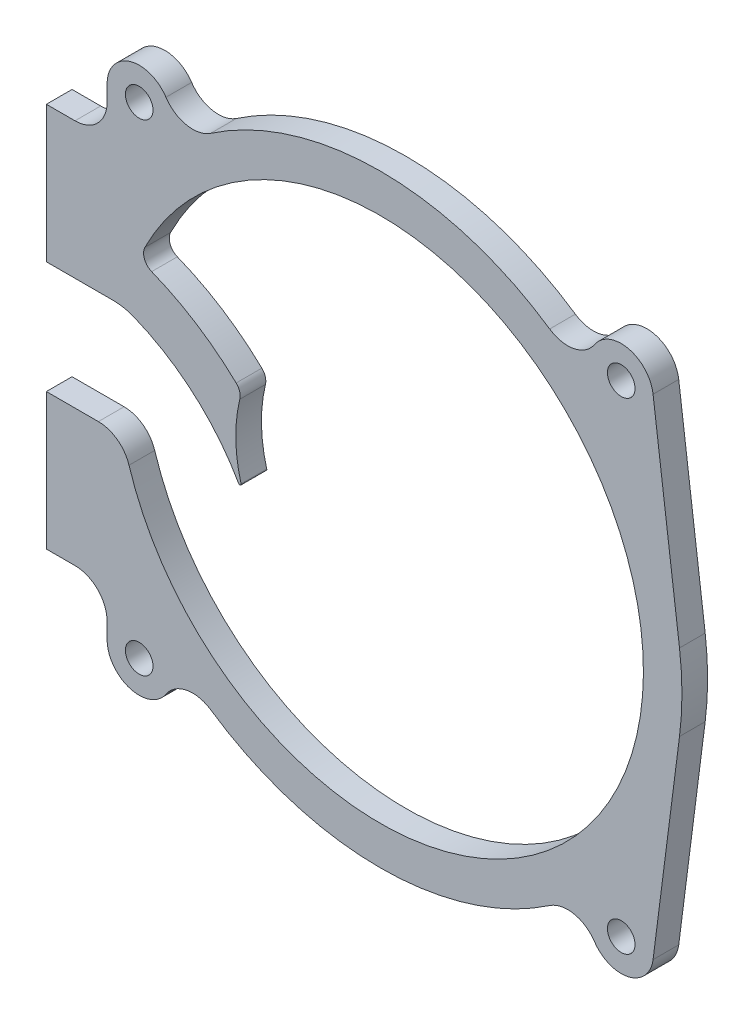
from build123d import *

# Parameters (mm, degrees)
SKETCH_1_R      = 2.15
EXTRUDE_1_DEPTH = 4
FILLET_1_R      = 0.2
FILLET_2_R      = 2
FILLET_3_R      = 2
FILLET_4_R      = 8.5
FILLET_5_R      = 5


with BuildPart() as part:
    # 草图1 → 凸台-拉伸1 (new body)
    with BuildSketch(Plane.XY):
        with BuildLine():
            Line((-52, 8.75), (-52, 30))
            Line((-52, 30), (-47.54, 30))
            ThreePointArc((-47.54, 30), (-44.004466094, 31.464466094), (-42.54, 35))
            Line((-42.54, 35), (-42.54, 37.5))
            ThreePointArc((-42.54, 37.5), (-38.982425028, 42.287422066), (-33.372235985, 40.262198963))
            ThreePointArc((-33.372235985, 40.262198963), (-30.171244586, 38.118753147), (-26.396349665, 38.887436588))
            ThreePointArc((-26.396349665, 38.887436588), (0, 47), (26.396349665, 38.887436588))
            ThreePointArc((26.396349665, 38.887436588), (30.171244586, 38.118753147), (33.372235985, 40.262198963))
            ThreePointArc((33.372235985, 40.262198963), (38.674773042, 42.369526686), (42.499484755, 38.135225128))
            Line((42.499484755, 38.135225128), (46.619156699, 5.971116201))
            ThreePointArc((46.619156699, 5.971116201), (47, 0), (46.619156699, -5.971116201))
            Line((46.619156699, -5.971116201), (42.499484755, -38.135225128))
            ThreePointArc((42.499484755, -38.135225128), (38.674773042, -42.369526686), (33.372235985, -40.262198963))
            ThreePointArc((33.372235985, -40.262198963), (30.171244586, -38.118753147), (26.396349665, -38.887436588))
            ThreePointArc((26.396349665, -38.887436588), (0, -47), (-26.396349665, -38.887436588))
            ThreePointArc((-26.396349665, -38.887436588), (-30.171244586, -38.118753147), (-33.372235985, -40.262198963))
            ThreePointArc((-33.372235985, -40.262198963), (-38.982425028, -42.287422066), (-42.54, -37.5))
            Line((-42.54, -37.5), (-42.54, -35))
            ThreePointArc((-42.54, -35), (-44.004466094, -31.464466094), (-47.54, -30))
            Line((-47.54, -30), (-52, -30))
            Line((-52, -30), (-52, -8.75))
            Line((-52, -8.75), (-40.055430343, -8.75))
            ThreePointArc((-40.055430343, -8.75), (40.804364959, -4.000475011), (-37.593370285, 16.362717092))
            ThreePointArc((-37.593370285, 16.362717092), (-29.005163231, 12.290176631), (-21.585495377, 6.349518825))
            ThreePointArc((-21.585495377, 6.349518825), (-22.451945258, -1.469746278), (-20.573530425, -9.10932741))
            ThreePointArc((-20.573530425, -9.10932741), (-28.44850534, 1.855840669), (-40.055430343, 8.75))
            Line((-40.055430343, 8.75), (-52, 8.75))
        make_face()
        with Locations((-37.54, 37.5)):
            Circle(SKETCH_1_R, mode=Mode.SUBTRACT)
        with Locations((-37.54, -37.5)):
            Circle(SKETCH_1_R, mode=Mode.SUBTRACT)
        with Locations((37.54, -37.5)):
            Circle(SKETCH_1_R, mode=Mode.SUBTRACT)
        with Locations((37.54, 37.5)):
            Circle(SKETCH_1_R, mode=Mode.SUBTRACT)
    extrude(amount=EXTRUDE_1_DEPTH)

    # 圆角1
    fillet_1_edges = [part.edges().sort_by_distance(p)[0] for p in [
        (-20.573530425, -9.10932741, 2),
    ]]
    fillet(fillet_1_edges, radius=FILLET_1_R)

    # 圆角2
    fillet_2_edges = [part.edges().sort_by_distance(p)[0] for p in [
        (-21.585495377, 6.349518825, 2),
    ]]
    fillet(fillet_2_edges, radius=FILLET_2_R)

    # 圆角3
    fillet_3_edges = [part.edges().sort_by_distance(p)[0] for p in [
        (-37.593370285, 16.362717092, 2),
    ]]
    fillet(fillet_3_edges, radius=FILLET_3_R)

    # 圆角4
    fillet_4_edges = [part.edges().sort_by_distance(p)[0] for p in [
        (-40.055430343, 8.75, 2),
    ]]
    fillet(fillet_4_edges, radius=FILLET_4_R)

    # 圆角5
    fillet_5_edges = [part.edges().sort_by_distance(p)[0] for p in [
        (-40.055430343, -8.75, 2),
    ]]
    fillet(fillet_5_edges, radius=FILLET_5_R)


solid = part.part
